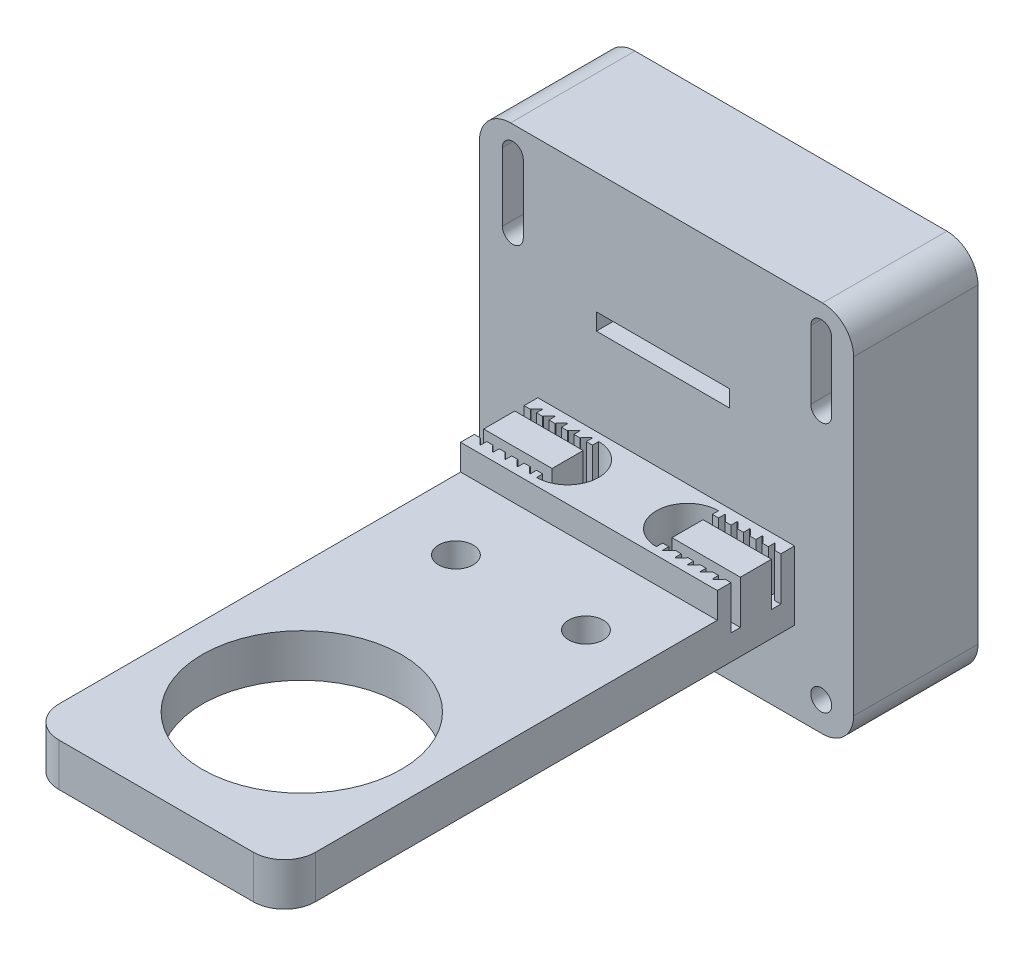
from build123d import *

# Parameters (mm, degrees)
CROQUIS1_W              = 60.14528302
CROQUIS1_H              = 60
CROQUIS1_R              = 1.678683546
CROQUIS1_W_2            = 21.375237152
CROQUIS1_H_2            = 2.685893673
SALIENTE_EXTRUIR1_DEPTH = 20
CROQUIS2_W              = 41.265919314
CROQUIS2_H              = 11.047137426
SALIENTE_EXTRUIR2_DEPTH = 82
CROQUIS3_W              = 22.519164753
CROQUIS3_H              = 7.541795743
CORTAR_EXTRUIR1_DEPTH   = 50
CROQUIS4_R              = 2.778810817
CORTAR_EXTRUIR2_DEPTH   = 52
REDONDEO1_R             = 5
REDONDEO2_R             = 5
CROQUIS5_R              = 16
CORTAR_EXTRUIR3_DEPTH   = 20
CROQUIS7_W              = 52.537645902
CROQUIS7_H              = 4.142676535
CORTAR_EXTRUIR4_DEPTH   = 62
CORTAR_EXTRUIR5_DEPTH   = 7


with BuildPart() as part:
    # Croquis1 → Saliente-Extruir1 (new body)
    with BuildSketch(Plane.XY):
        with Locations((3.000280638, -1.75)):
            Rectangle(CROQUIS1_W, CROQUIS1_H)
        with Locations((27.873314814, -27.085103986)):
            Circle(CROQUIS1_R, mode=Mode.SUBTRACT)
        with Locations((-21.703805911, -27.085103986)):
            Circle(CROQUIS1_R, mode=Mode.SUBTRACT)
        with Locations((2.413281033, 7.495777062)):
            Rectangle(CROQUIS1_W_2, CROQUIS1_H_2, mode=Mode.SUBTRACT)
        with BuildLine():
            Line((-20.025122365, 24.170700285), (-20.025122365, 13.203301118))
            ThreePointArc((-20.025122365, 13.203301118), (-21.703805911, 11.524617572), (-23.382489457, 13.203301118))
            Line((-23.382489457, 13.203301118), (-23.382489457, 24.170700285))
            ThreePointArc((-23.382489457, 24.170700285), (-21.703805911, 25.849383831), (-20.025122365, 24.170700285))
        make_face(mode=Mode.SUBTRACT)
        with BuildLine():
            Line((29.55199836, 24.170700285), (29.55199836, 13.203301118))
            ThreePointArc((29.55199836, 13.203301118), (27.873314814, 11.524617572), (26.194631268, 13.203301118))
            Line((26.194631268, 13.203301118), (26.194631268, 24.170700285))
            ThreePointArc((26.194631268, 24.170700285), (27.873314814, 25.849383831), (29.55199836, 24.170700285))
        make_face(mode=Mode.SUBTRACT)
    extrude(amount=SALIENTE_EXTRUIR1_DEPTH)

    # Croquis2 → Saliente-Extruir2 (add)
    with BuildSketch(Plane.XY.offset(20)):
        with Locations((2.946265977, -13.343146768)):
            Rectangle(CROQUIS2_W, CROQUIS2_H)
    extrude(amount=SALIENTE_EXTRUIR2_DEPTH)

    # Croquis3 → Cortar-Extruir1 (cut)
    with BuildSketch(Plane(origin=(23.579225634, 0, 0), x_dir=(0, 0, -1), z_dir=(1, 0, 0))):
        with Locations((-43.67389367, -8.191356718)):
            Rectangle(CROQUIS3_W, CROQUIS3_H)
    extrude(amount=-CORTAR_EXTRUIR1_DEPTH, mode=Mode.SUBTRACT)

    # Croquis4 → Cortar-Extruir2 (cut)
    with BuildSketch(Plane.XZ.offset(18.866715481)):
        with Locations((-6.523695114, 44.333086762)):
            Circle(CROQUIS4_R)
        with Locations((14.386898359, 44.333086762)):
            Circle(CROQUIS4_R)
    extrude(amount=-CORTAR_EXTRUIR2_DEPTH, mode=Mode.SUBTRACT)

    # Redondeo1
    redondeo1_edges = [part.edges().sort_by_distance(p)[0] for p in [
        (-17.68669368, -13.343146768, 102),
        (23.579225634, -13.343146768, 102),
    ]]
    fillet(redondeo1_edges, radius=REDONDEO1_R)

    # Redondeo2
    redondeo2_edges = [part.edges().sort_by_distance(p)[0] for p in [
        (-27.072360872, 28.25, 10),
        (33.072922148, 28.25, 10),
        (33.072922148, -31.75, 10),
        (-27.072360872, -31.75, 10),
    ]]
    fillet(redondeo2_edges, radius=REDONDEO2_R)

    # Croquis5 → Cortar-Extruir3 (cut)
    with BuildSketch(Plane(origin=(0, -7.819578055, 0), x_dir=(1, 0, 0), z_dir=(0, 1, 0))):
        with Locations((2.946265977, -78.573452579)):
            Circle(CROQUIS5_R)
    extrude(amount=-CORTAR_EXTRUIR3_DEPTH, mode=Mode.SUBTRACT)

    # Croquis7 → Cortar-Extruir4 (cut)
    with BuildSketch(Plane.ZY.offset(17.68669368)):
        with Locations((81.202298997, -9.890916323)):
            Rectangle(CROQUIS7_W, CROQUIS7_H)
    extrude(amount=-CORTAR_EXTRUIR4_DEPTH, mode=Mode.SUBTRACT)

    # Croquis8 → Cortar-Extruir5 (cut)
    with BuildSketch(Plane(origin=(0, -7.819578055, 0), x_dir=(1, 0, 0), z_dir=(0, 1, 0))):
        with BuildLine():
            Line((-8.68669368, -30.207155647), (-8.68669368, -30.307155647))
            Line((-8.68669368, -30.307155647), (-7.78669368, -31.207155647))
            Line((-7.78669368, -31.207155647), (-7.68669368, -31.207155647))
            Line((-7.68669368, -31.207155647), (-7.68669368, -30.207155647))
            Line((-7.68669368, -30.207155647), (-6.68669368, -30.207155647))
            Line((-6.68669368, -30.207155647), (-6.68669368, -31.207155647))
            ThreePointArc((-6.68669368, -31.207155647), (-1.68669368, -26.207155647), (-6.68669368, -21.207155647))
            Line((-6.68669368, -21.207155647), (-6.68669368, -22.207155647))
            Line((-6.68669368, -22.207155647), (-7.68669368, -22.207155647))
            Line((-7.68669368, -22.207155647), (-7.68669368, -21.207155647))
            Line((-7.68669368, -21.207155647), (-7.78669368, -21.207155647))
            Line((-7.78669368, -21.207155647), (-8.68669368, -22.107155647))
            Line((-8.68669368, -22.107155647), (-8.68669368, -22.207155647))
            Line((-8.68669368, -22.207155647), (-9.68669368, -22.207155647))
            Line((-9.68669368, -22.207155647), (-9.68669368, -21.207155647))
            Line((-9.68669368, -21.207155647), (-9.78669368, -21.207155647))
            Line((-9.78669368, -21.207155647), (-10.68669368, -22.107155647))
            Line((-10.68669368, -22.107155647), (-10.68669368, -22.207155647))
            Line((-10.68669368, -22.207155647), (-11.68669368, -22.207155647))
            Line((-11.68669368, -22.207155647), (-11.68669368, -21.207155647))
            Line((-11.68669368, -21.207155647), (-11.78669368, -21.207155647))
            Line((-11.78669368, -21.207155647), (-12.68669368, -22.107155647))
            Line((-12.68669368, -22.107155647), (-12.68669368, -22.207155647))
            Line((-12.68669368, -22.207155647), (-13.68669368, -22.207155647))
            Line((-13.68669368, -22.207155647), (-13.68669368, -21.207155647))
            Line((-13.68669368, -21.207155647), (-13.78669368, -21.207155647))
            Line((-13.78669368, -21.207155647), (-14.68669368, -22.107155647))
            Line((-14.68669368, -22.107155647), (-14.68669368, -22.207155647))
            Line((-14.68669368, -22.207155647), (-15.68669368, -22.207155647))
            Line((-15.68669368, -22.207155647), (-15.68669368, -21.207155647))
            Line((-15.68669368, -21.207155647), (-15.78669368, -21.207155647))
            Line((-15.78669368, -21.207155647), (-16.68669368, -22.107155647))
            Line((-16.68669368, -22.107155647), (-16.68669368, -22.207155647))
            Line((-16.68669368, -22.207155647), (-17.68669368, -22.207155647))
            Line((-17.68669368, -22.207155647), (-17.68669368, -23.707155647))
            Line((-17.68669368, -23.707155647), (-6.68669368, -23.707155647))
            Line((-6.68669368, -23.707155647), (-6.68669368, -28.707155647))
            Line((-6.68669368, -28.707155647), (-17.68669368, -28.707155647))
            Line((-17.68669368, -28.707155647), (-17.68669368, -30.207155647))
            Line((-17.68669368, -30.207155647), (-16.68669368, -30.207155647))
            Line((-16.68669368, -30.207155647), (-16.68669368, -30.307155647))
            Line((-16.68669368, -30.307155647), (-15.78669368, -31.207155647))
            Line((-15.78669368, -31.207155647), (-15.68669368, -31.207155647))
            Line((-15.68669368, -31.207155647), (-15.68669368, -30.207155647))
            Line((-15.68669368, -30.207155647), (-14.68669368, -30.207155647))
            Line((-14.68669368, -30.207155647), (-14.68669368, -30.307155647))
            Line((-14.68669368, -30.307155647), (-13.78669368, -31.207155647))
            Line((-13.78669368, -31.207155647), (-13.68669368, -31.207155647))
            Line((-13.68669368, -31.207155647), (-13.68669368, -30.207155647))
            Line((-13.68669368, -30.207155647), (-12.68669368, -30.207155647))
            Line((-12.68669368, -30.207155647), (-12.68669368, -30.307155647))
            Line((-12.68669368, -30.307155647), (-11.78669368, -31.207155647))
            Line((-11.78669368, -31.207155647), (-11.68669368, -31.207155647))
            Line((-11.68669368, -31.207155647), (-11.68669368, -30.207155647))
            Line((-11.68669368, -30.207155647), (-10.68669368, -30.207155647))
            Line((-10.68669368, -30.207155647), (-10.68669368, -30.307155647))
            Line((-10.68669368, -30.307155647), (-9.78669368, -31.207155647))
            Line((-9.78669368, -31.207155647), (-9.68669368, -31.207155647))
            Line((-9.68669368, -31.207155647), (-9.68669368, -30.207155647))
            Line((-9.68669368, -30.207155647), (-8.68669368, -30.207155647))
        make_face()
        with BuildLine():
            Line((22.579225634, -30.207155647), (23.579225634, -30.207155647))
            Line((23.579225634, -30.207155647), (23.579225634, -28.707155647))
            Line((23.579225634, -28.707155647), (12.579225634, -28.707155647))
            Line((12.579225634, -28.707155647), (12.579225634, -23.707155647))
            Line((12.579225634, -23.707155647), (23.579225634, -23.707155647))
            Line((23.579225634, -23.707155647), (23.579225634, -22.207155647))
            Line((23.579225634, -22.207155647), (22.579225634, -22.207155647))
            Line((22.579225634, -22.207155647), (22.579225634, -22.107155647))
            Line((22.579225634, -22.107155647), (21.679225634, -21.207155647))
            Line((21.679225634, -21.207155647), (21.579225634, -21.207155647))
            Line((21.579225634, -21.207155647), (21.579225634, -22.207155647))
            Line((21.579225634, -22.207155647), (20.579225634, -22.207155647))
            Line((20.579225634, -22.207155647), (20.579225634, -22.107155647))
            Line((20.579225634, -22.107155647), (19.679225634, -21.207155647))
            Line((19.679225634, -21.207155647), (19.579225634, -21.207155647))
            Line((19.579225634, -21.207155647), (19.579225634, -22.207155647))
            Line((19.579225634, -22.207155647), (18.579225634, -22.207155647))
            Line((18.579225634, -22.207155647), (18.579225634, -22.107155647))
            Line((18.579225634, -22.107155647), (17.679225634, -21.207155647))
            Line((17.679225634, -21.207155647), (17.579225634, -21.207155647))
            Line((17.579225634, -21.207155647), (17.579225634, -22.207155647))
            Line((17.579225634, -22.207155647), (16.579225634, -22.207155647))
            Line((16.579225634, -22.207155647), (16.579225634, -22.107155647))
            Line((16.579225634, -22.107155647), (15.679225634, -21.207155647))
            Line((15.679225634, -21.207155647), (15.579225634, -21.207155647))
            Line((15.579225634, -21.207155647), (15.579225634, -22.207155647))
            Line((15.579225634, -22.207155647), (14.579225634, -22.207155647))
            Line((14.579225634, -22.207155647), (14.579225634, -22.107155647))
            Line((14.579225634, -22.107155647), (13.679225634, -21.207155647))
            Line((13.679225634, -21.207155647), (13.579225634, -21.207155647))
            Line((13.579225634, -21.207155647), (13.579225634, -22.207155647))
            Line((13.579225634, -22.207155647), (12.579225634, -22.207155647))
            Line((12.579225634, -22.207155647), (12.579225634, -21.207155647))
            ThreePointArc((12.579225634, -21.207155647), (7.579225634, -26.207155647), (12.579225634, -31.207155647))
            Line((12.579225634, -31.207155647), (12.579225634, -30.207155647))
            Line((12.579225634, -30.207155647), (13.579225634, -30.207155647))
            Line((13.579225634, -30.207155647), (13.579225634, -31.207155647))
            Line((13.579225634, -31.207155647), (13.679225634, -31.207155647))
            Line((13.679225634, -31.207155647), (14.579225634, -30.307155647))
            Line((14.579225634, -30.307155647), (14.579225634, -30.207155647))
            Line((14.579225634, -30.207155647), (15.579225634, -30.207155647))
            Line((15.579225634, -30.207155647), (15.579225634, -31.207155647))
            Line((15.579225634, -31.207155647), (15.679225634, -31.207155647))
            Line((15.679225634, -31.207155647), (16.579225634, -30.307155647))
            Line((16.579225634, -30.307155647), (16.579225634, -30.207155647))
            Line((16.579225634, -30.207155647), (17.579225634, -30.207155647))
            Line((17.579225634, -30.207155647), (17.579225634, -31.207155647))
            Line((17.579225634, -31.207155647), (17.679225634, -31.207155647))
            Line((17.679225634, -31.207155647), (18.579225634, -30.307155647))
            Line((18.579225634, -30.307155647), (18.579225634, -30.207155647))
            Line((18.579225634, -30.207155647), (19.579225634, -30.207155647))
            Line((19.579225634, -30.207155647), (19.579225634, -31.207155647))
            Line((19.579225634, -31.207155647), (19.679225634, -31.207155647))
            Line((19.679225634, -31.207155647), (20.579225634, -30.307155647))
            Line((20.579225634, -30.307155647), (20.579225634, -30.207155647))
            Line((20.579225634, -30.207155647), (21.579225634, -30.207155647))
            Line((21.579225634, -30.207155647), (21.579225634, -31.207155647))
            Line((21.579225634, -31.207155647), (21.679225634, -31.207155647))
            Line((21.679225634, -31.207155647), (22.579225634, -30.307155647))
            Line((22.579225634, -30.307155647), (22.579225634, -30.207155647))
        make_face()
    extrude(amount=-CORTAR_EXTRUIR5_DEPTH, mode=Mode.SUBTRACT)


solid = part.part
